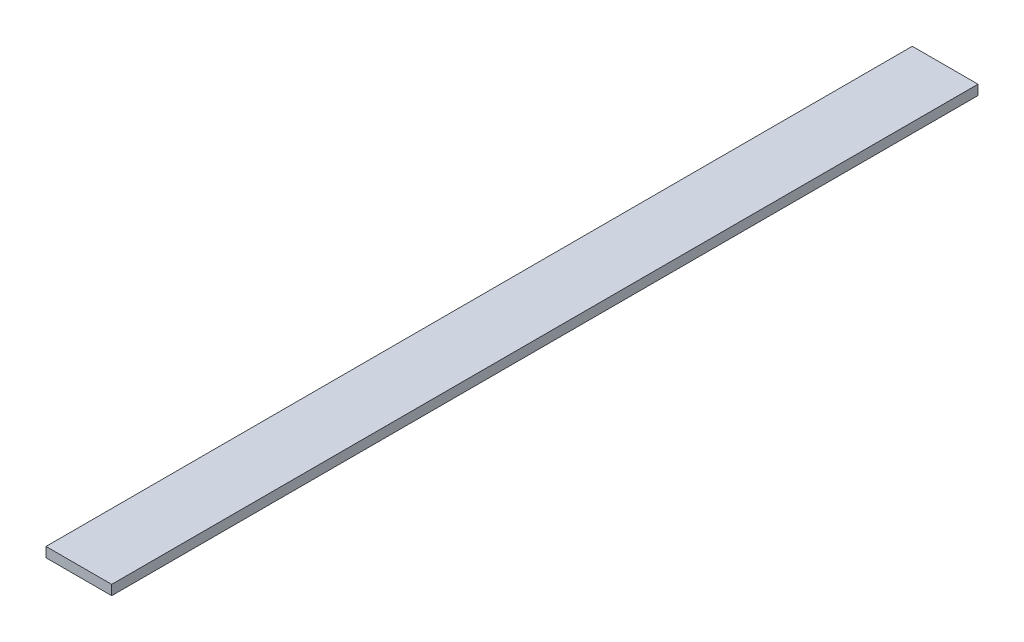
from build123d import *

# Parameters (mm, degrees)
SKETCH1_W           = 30
SKETCH1_H           = 404
BOSS_EXTRUDE1_DEPTH = 4.5
SKETCH2_W           = 8.37
SKETCH2_H           = 4.5
CUT_EXTRUDE1_DEPTH  = 40


with BuildPart() as part:
    # Sketch1 → Boss-Extrude1 (new body)
    with BuildSketch(Plane(origin=(0, 0, 0), x_dir=(1, 0, 0), z_dir=(0, 1, 0))):
        with Locations((-21.516129032, 114.756272401)):
            Rectangle(SKETCH1_W, SKETCH1_H)
    extrude(amount=BOSS_EXTRUDE1_DEPTH)

    # Sketch2 → Cut-Extrude1 (cut)
    with BuildSketch(Plane(origin=(-6.516129032, 0, 0), x_dir=(0, 0, -1), z_dir=(1, 0, 0))):
        with Locations((-83.058727599, 2.25)):
            Rectangle(SKETCH2_W, SKETCH2_H)
    extrude(amount=-CUT_EXTRUDE1_DEPTH, mode=Mode.SUBTRACT)


solid = part.part
